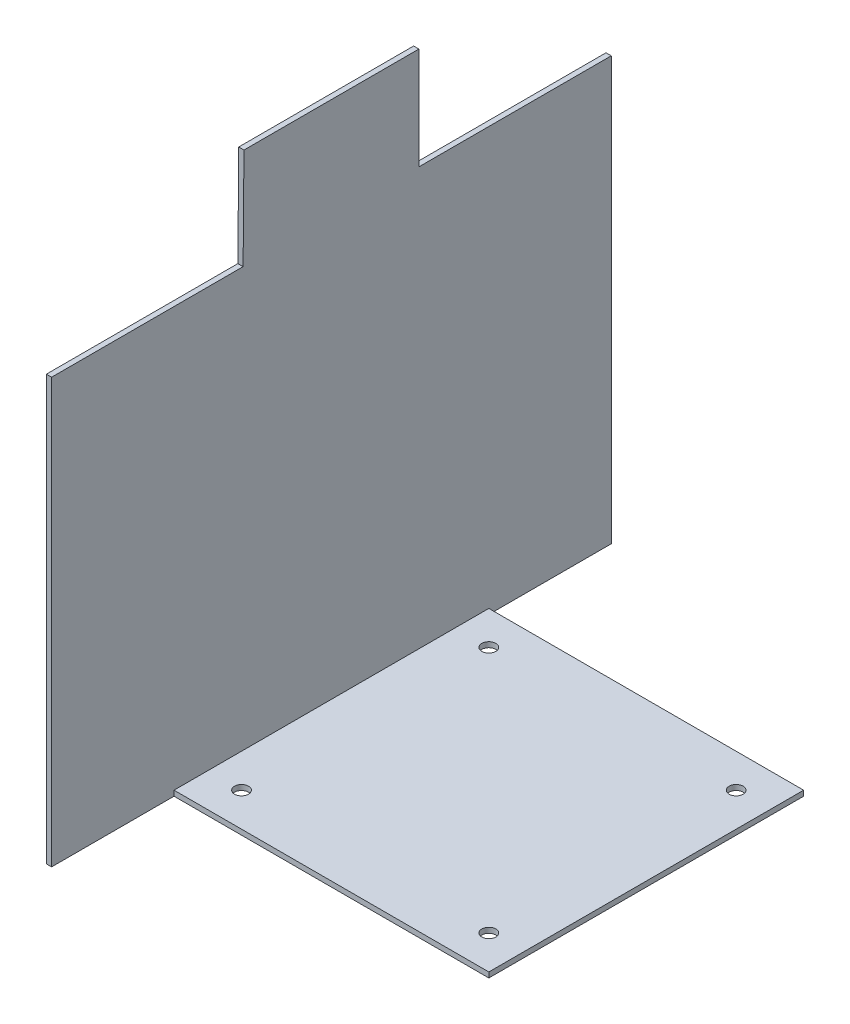
from build123d import *

# Parameters (mm, degrees)
SKETCH1_W           = 320
SKETCH1_H           = 300
BOSS_EXTRUDE1_DEPTH = 3
SKETCH2_W           = 180
SKETCH2_H           = 180
SKETCH2_R           = 4
BOSS_EXTRUDE2_DEPTH = 3
CUT_EXTRUDE1_DEPTH  = 10


with BuildPart() as part:
    # Sketch1 → Boss-Extrude1 (new body)
    with BuildSketch(Plane(origin=(0, 0, 0), x_dir=(0, 0, -1), z_dir=(1, 0, 0))):
        Rectangle(SKETCH1_W, SKETCH1_H)
    extrude(amount=BOSS_EXTRUDE1_DEPTH)

    # Sketch2 → Boss-Extrude2 (add)
    with BuildSketch(Plane.XZ.offset(150)):
        with Locations((93, 0)):
            Rectangle(SKETCH2_W, SKETCH2_H)
        with Locations((22.29, -70.71)):
            Circle(SKETCH2_R, mode=Mode.SUBTRACT)
        with Locations((22.29, 70.71)):
            Circle(SKETCH2_R, mode=Mode.SUBTRACT)
        with Locations((163.71, 70.71)):
            Circle(SKETCH2_R, mode=Mode.SUBTRACT)
        with Locations((163.71, -70.71)):
            Circle(SKETCH2_R, mode=Mode.SUBTRACT)
    extrude(amount=-BOSS_EXTRUDE2_DEPTH)

    # Sketch3 → Cut-Extrude1 (cut)
    with BuildSketch(Plane(origin=(3, 0, 0), x_dir=(0, 0, -1), z_dir=(1, 0, 0))):
        Polygon((-50, 152), (-50.5, 92.5), (-174.995322546, 92.5), (-174.995322546, 153.849759006), (-150, 158.899747984), align=None)
        Polygon((186.01679007, 162.206902793), (50, 152), (50, 91.655462185), (186.01679007, 91.655462185), align=None)
    extrude(amount=-CUT_EXTRUDE1_DEPTH, mode=Mode.SUBTRACT)


solid = part.part
